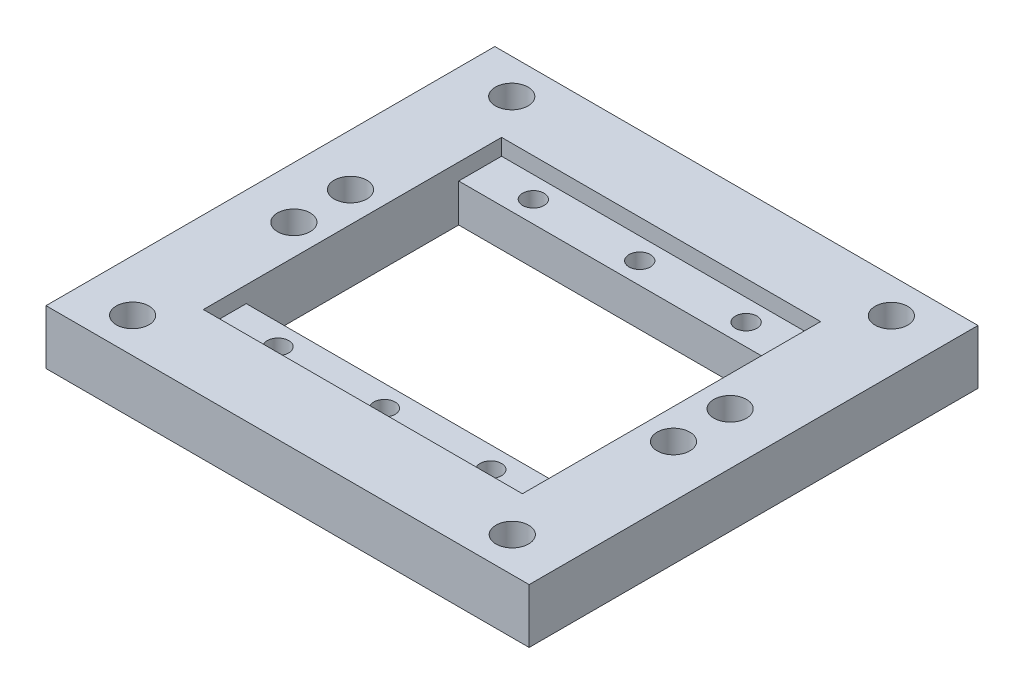
from build123d import *

# Parameters (mm, degrees)
SKETCH2_W           = 112.649
SKETCH2_H           = 104.648
SKETCH2_R           = 3.81
BOSS_EXTRUDE5_DEPTH = 12.7
SKETCH2_4_W         = 74.389
SKETCH2_4_H         = 10
SKETCH2_4_R         = 2.5
BOSS_EXTRUDE7_DEPTH = 8.89


with BuildPart() as part:
    # Sketch2 → Boss-Extrude5 (new body)
    with BuildSketch(Plane(origin=(0, 0, 0), x_dir=(1, 0, 0), z_dir=(0, 1, 0))):
        with Locations((56.3245, 52.324)):
            Rectangle(SKETCH2_W, SKETCH2_H)
        with Locations((12.065, 8.128)):
            Circle(SKETCH2_R, mode=Mode.SUBTRACT)
        with Locations((12.065, 45.72)):
            Circle(SKETCH2_R, mode=Mode.SUBTRACT)
        with Locations((100.584, 8.128)):
            Circle(SKETCH2_R, mode=Mode.SUBTRACT)
        Polygon((19.13, 17.559), (19.13, 27.559), (19.13, 77.089), (19.13, 87.089), (93.519, 87.089), (93.519, 77.089), (93.519, 27.559), (93.519, 17.559), align=None, mode=Mode.SUBTRACT)
        with Locations((100.584, 45.72)):
            Circle(SKETCH2_R, mode=Mode.SUBTRACT)
        with Locations((12.065, 58.928)):
            Circle(SKETCH2_R, mode=Mode.SUBTRACT)
        with Locations((12.065, 96.52)):
            Circle(SKETCH2_R, mode=Mode.SUBTRACT)
        with Locations((100.584, 58.928)):
            Circle(SKETCH2_R, mode=Mode.SUBTRACT)
        with Locations((100.584, 96.52)):
            Circle(SKETCH2_R, mode=Mode.SUBTRACT)
    extrude(amount=BOSS_EXTRUDE5_DEPTH)

    # Sketch2_4 → Boss-Extrude7 (add)
    # profile 1 of 2: a face of its own
    with BuildSketch(Plane(origin=(0, 0, 0), x_dir=(1, 0, 0), z_dir=(0, 1, 0))):
        with Locations((56.3245, 22.559)):
            Rectangle(SKETCH2_4_W, SKETCH2_4_H)
        with Locations((31.533666667, 22.559)):
            Circle(SKETCH2_4_R, mode=Mode.SUBTRACT)
        with Locations((56.341, 22.559)):
            Circle(SKETCH2_4_R, mode=Mode.SUBTRACT)
        with Locations((81.148333333, 22.559)):
            Circle(SKETCH2_4_R, mode=Mode.SUBTRACT)
    # profile 2 of 2: a face of its own
    with BuildSketch(Plane(origin=(0, 0, 0), x_dir=(1, 0, 0), z_dir=(0, 1, 0))):
        with Locations((56.3245, 82.089)):
            Rectangle(SKETCH2_4_W, SKETCH2_4_H)
        with Locations((31.533666667, 82.089)):
            Circle(SKETCH2_4_R, mode=Mode.SUBTRACT)
        with Locations((56.341, 82.089)):
            Circle(SKETCH2_4_R, mode=Mode.SUBTRACT)
        with Locations((81.148333333, 82.089)):
            Circle(SKETCH2_4_R, mode=Mode.SUBTRACT)
    extrude(amount=BOSS_EXTRUDE7_DEPTH)


solid = part.part
